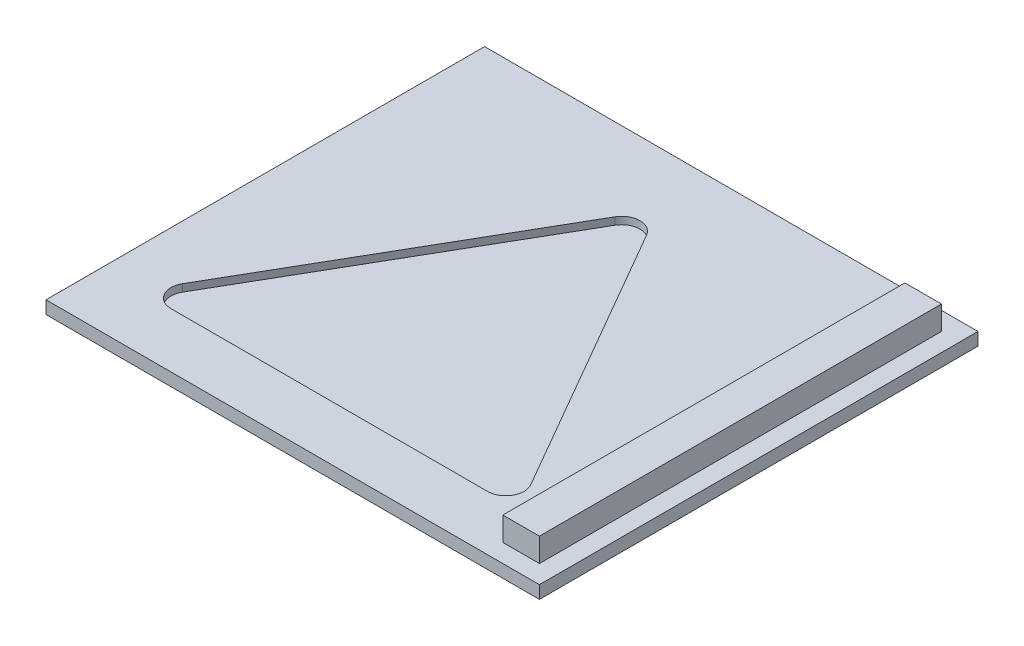
from build123d import *

# Parameters (mm, degrees)
SKETCH1_W           = 26
SKETCH1_H           = 24
BOSS_EXTRUDE1_DEPTH = 0.7
SKETCH2_W           = 2
SKETCH2_H           = 22
BOSS_EXTRUDE2_DEPTH = 1.3
CUT_EXTRUDE2_DEPTH  = 0.4
SKETCH4_W           = 1
SKETCH4_H           = 24
BOSS_EXTRUDE3_DEPTH = 0.7


with BuildPart() as part:
    # Sketch1 → Boss-Extrude1 (new body)
    with BuildSketch(Plane(origin=(0, 0, 0), x_dir=(1, 0, 0), z_dir=(0, 1, 0))):
        Rectangle(SKETCH1_W, SKETCH1_H)
    extrude(amount=BOSS_EXTRUDE1_DEPTH)

    # Sketch2 → Boss-Extrude2 (add)
    with BuildSketch(Plane(origin=(0, 0.7, 0), x_dir=(1, 0, 0), z_dir=(0, 1, 0))):
        with Locations((11, 0)):
            Rectangle(SKETCH2_W, SKETCH2_H)
    extrude(amount=BOSS_EXTRUDE2_DEPTH)

    # Sketch3 → Cut-Extrude2 (cut)
    with BuildSketch(Plane(origin=(0, 0.7, 0), x_dir=(1, 0, 0), z_dir=(0, 1, 0))):
        with BuildLine():
            Line((-2.366025404, 7.5), (-11.026279442, -7.5))
            ThreePointArc((-11.026279442, -7.5), (-11.026279442, -8.5), (-10.160254038, -9))
            Line((-10.160254038, -9), (7.160254038, -9))
            ThreePointArc((7.160254038, -9), (8.026279442, -8.5), (8.026279442, -7.5))
            Line((8.026279442, -7.5), (-0.633974596, 7.5))
            ThreePointArc((-0.633974596, 7.5), (-1.5, 8), (-2.366025404, 7.5))
        make_face()
    extrude(amount=-CUT_EXTRUDE2_DEPTH, mode=Mode.SUBTRACT)

    # Sketch4 → Boss-Extrude3 (add)
    with BuildSketch(Plane(origin=(0, 0.7, 0), x_dir=(1, 0, 0), z_dir=(0, 1, 0))):
        with Locations((-13.5, 0)):
            Rectangle(SKETCH4_W, SKETCH4_H)
    extrude(amount=-BOSS_EXTRUDE3_DEPTH)


solid = part.part
